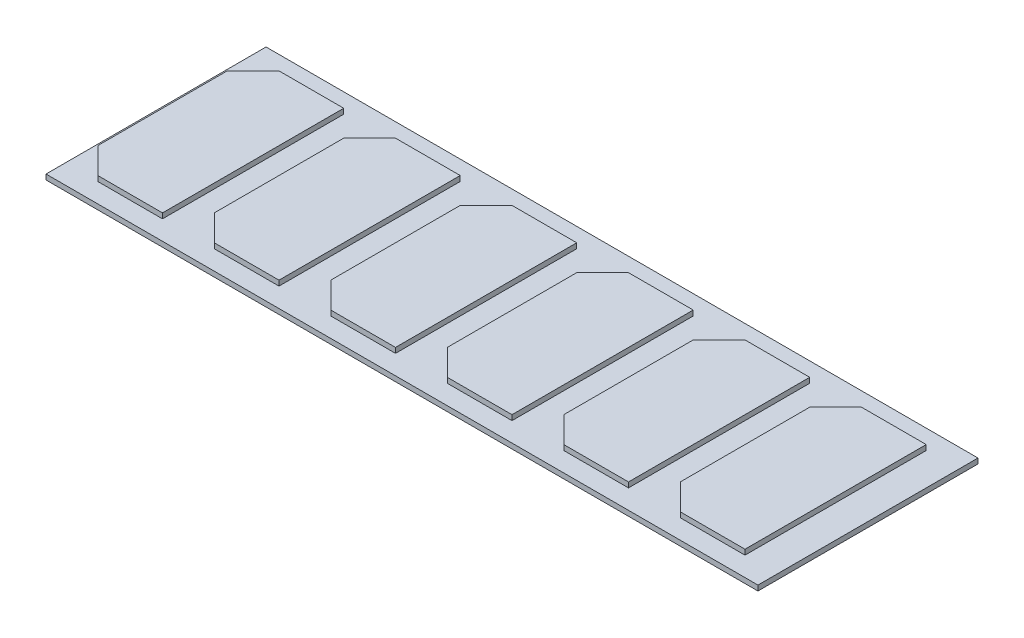
from build123d import *

# Parameters (mm, degrees)
SKETCH1_W           = 275
SKETCH1_H           = 85
BOSS_EXTRUDE1_DEPTH = 2
BOSS_EXTRUDE2_DEPTH = 2


with BuildPart() as part:
    # Sketch1 → Boss-Extrude1 (new body)
    with BuildSketch(Plane(origin=(0, 0, 0), x_dir=(1, 0, 0), z_dir=(0, 1, 0))):
        Rectangle(SKETCH1_W, SKETCH1_H)
    extrude(amount=BOSS_EXTRUDE1_DEPTH)

    # Sketch2 → Boss-Extrude2 (add)
    with BuildSketch(Plane(origin=(0, 2, 0), x_dir=(1, 0, 0), z_dir=(0, 1, 0))):
        Polygon((-100, 35), (-100, -35), (-125, -35), (-135, -25), (-135, 25), (-125, 35), align=None)
        Polygon((-90, 25), (-80, 35), (-55, 35), (-55, -35), (-80, -35), (-90, -25), align=None)
        Polygon((-45, 25), (-35, 35), (-10, 35), (-10, -35), (-35, -35), (-45, -25), align=None)
        Polygon((0, 25), (10, 35), (35, 35), (35, -35), (10, -35), (0, -25), align=None)
        Polygon((45, 25), (55, 35), (80, 35), (80, -35), (55, -35), (45, -25), align=None)
        Polygon((90, 25), (100, 35), (125, 35), (125, -35), (100, -35), (90, -25), align=None)
    extrude(amount=BOSS_EXTRUDE2_DEPTH)


solid = part.part
